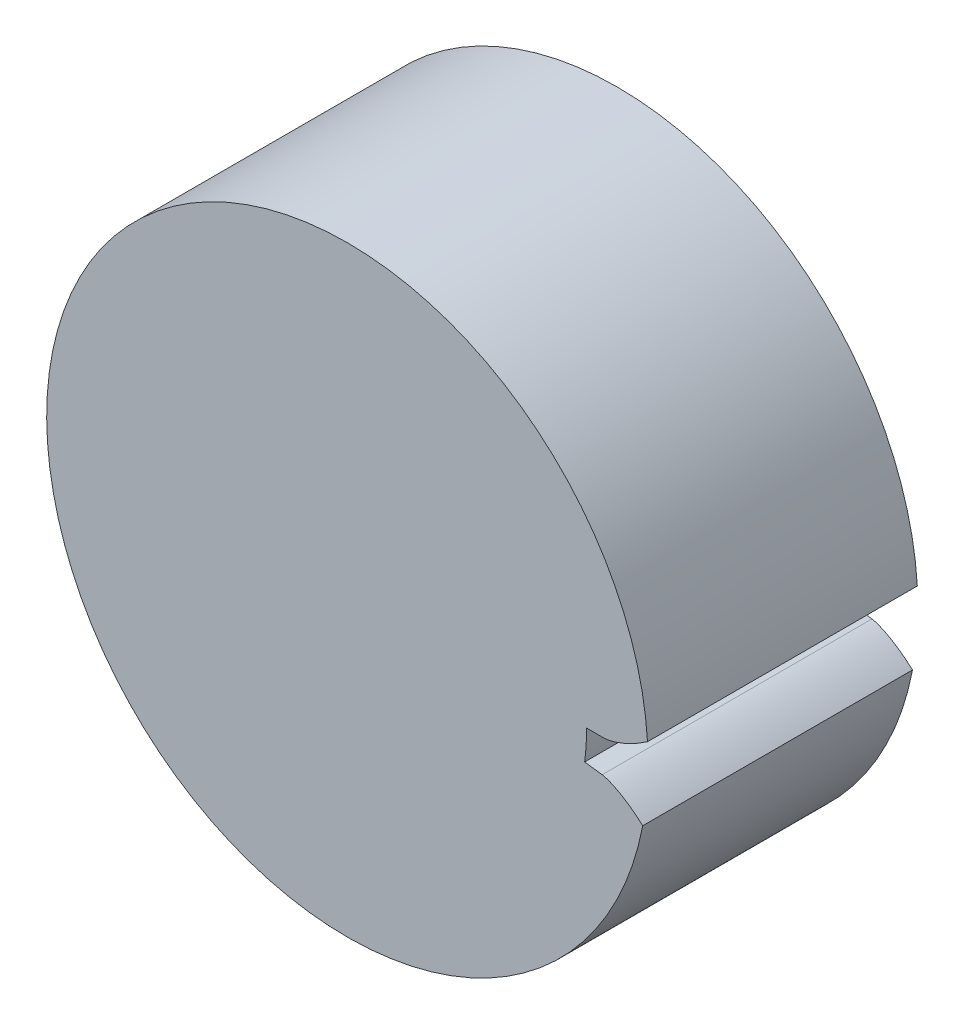
from build123d import *

# Parameters (mm, degrees)
SKETCH1_R               = 24.53
BOSS_EXTRUDE1_DEPTH     = 22.008152455
CUT_EXTRUDE3_DEPTH      = 23.008152455
CUT_EXTRUDE3_DEPTH_BACK = 1


with BuildPart() as part:
    # Sketch1 → Boss-Extrude1 (new body)
    with BuildSketch(Plane.XY):
        Circle(SKETCH1_R)
    extrude(amount=BOSS_EXTRUDE1_DEPTH)

    # Sketch2 → Cut-Extrude3 (cut, two sides)
    with BuildSketch(Plane.XY) as cut_extrude3_sk:
        with BuildLine():
            Line((20.955145444, 0), (19.5125, 0))
            ThreePointArc((19.5125, 0), (19.473005706, -1.240848518), (19.354682699, -2.476673954))
            Line((19.354682699, -2.476673954), (20.785660011, -2.659785415))
            add(Edge.make_bspline(
                [(20.785660011, -2.659785415), (20.800985299, -2.662076983), (20.843806968, -2.669507053), (20.924073429, -2.687499122), (21.05378572, -2.72241867), (21.216979197, -2.774995556), (21.425137234, -2.852162258), (21.666388368, -2.954705307), (21.926945547, -3.07951949), (22.20493909, -3.228005325), (22.477187641, -3.387439173), (22.743526717, -3.556434161), (23.004180465, -3.734229594), (23.313555372, -3.959446459), (23.619528341, -4.200366277), (23.856411219, -4.400665356), (24.029365424, -4.554471972), (24.092590531, -4.611722182)],
                knots=[0, 0, 0, 0, 0, 0.005376748, 0.015083688, 0.02853182, 0.046610139, 0.064854849, 0.092110525, 0.119476175, 0.146842495, 0.174208853, 0.201574955, 0.228941013, 0.256307345, 0.307035032, 0.336633369, 0.336633369, 0.336633369, 0.336633369, 0.336633369], degree=4))
            ThreePointArc((24.092590531, -4.611722182), (24.420402799, -2.316209648), (24.53, 0))
            ThreePointArc((24.53, 0), (24.518268205, 0.75856723), (24.483084041, 1.51640887))
            add(Edge.make_bspline(
                [(20.955145444, 0), (20.970637643, 0.000327832), (21.014056051, 0.002262558), (21.095957005, 0.009921081), (21.229052435, 0.028094135), (21.397599457, 0.059532029), (21.613868491, 0.109653615), (21.866183922, 0.180745878), (22.140476071, 0.271478677), (22.435068144, 0.383478516), (22.725351294, 0.507067017), (23.010986338, 0.640889404), (23.292099055, 0.784162682), (23.627557961, 0.96828979), (23.961635582, 1.168424644), (24.222026021, 1.337036737), (24.413103669, 1.467646709), (24.483084041, 1.51640887)],
                knots=[0, 0, 0, 0, 0, 0.005376748, 0.015083688, 0.02853182, 0.046610139, 0.064854849, 0.092110525, 0.119476175, 0.146842495, 0.174208853, 0.201574955, 0.228941013, 0.256307345, 0.307035032, 0.336633369, 0.336633369, 0.336633369, 0.336633369, 0.336633369], degree=4))
        make_face()
    extrude(amount=CUT_EXTRUDE3_DEPTH, mode=Mode.SUBTRACT)
    extrude(cut_extrude3_sk.sketch, amount=-CUT_EXTRUDE3_DEPTH_BACK, mode=Mode.SUBTRACT)


solid = part.part
